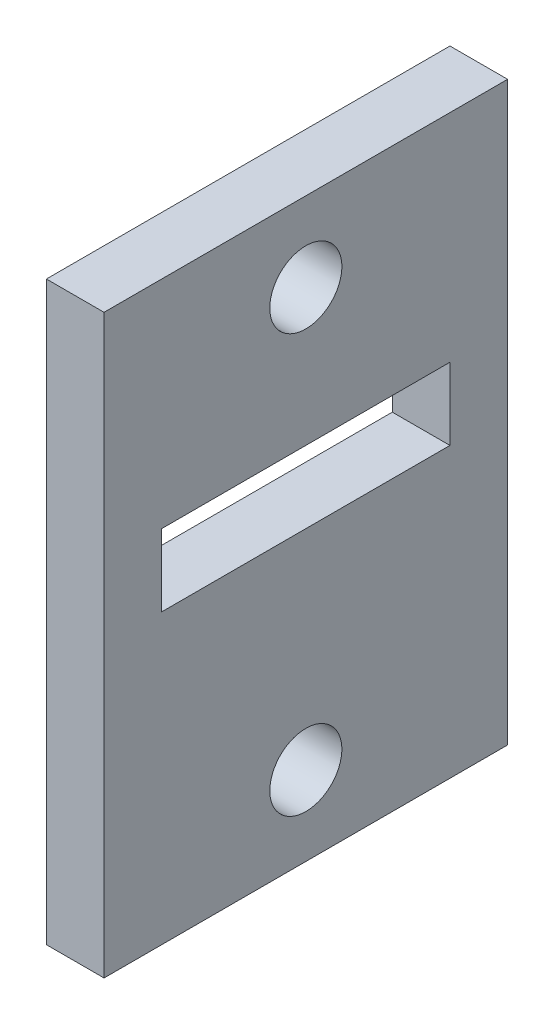
from build123d import *

# Parameters (mm, degrees)
SKETCH1_W           = 14
SKETCH1_H           = 20
SKETCH1_R           = 1.25
BOSS_EXTRUDE1_DEPTH = 2
SKETCH2_W           = 10
SKETCH2_H           = 2.5
CUT_EXTRUDE1_DEPTH  = 2


with BuildPart() as part:
    # Sketch1 → Boss-Extrude1 (new body)
    with BuildSketch(Plane.ZY.offset(64.057810508)):
        with Locations((25, -3.601413474)):
            Rectangle(SKETCH1_W, SKETCH1_H)
        with Locations((25, -10.851413474)):
            Circle(SKETCH1_R, mode=Mode.SUBTRACT)
        with Locations((25, 3.648586526)):
            Circle(SKETCH1_R, mode=Mode.SUBTRACT)
    extrude(amount=BOSS_EXTRUDE1_DEPTH)

    # Sketch2 → Cut-Extrude1 (cut)
    with BuildSketch(Plane.ZY.offset(66.057810508)):
        with Locations((25, -2.351413474)):
            Rectangle(SKETCH2_W, SKETCH2_H)
    extrude(amount=-CUT_EXTRUDE1_DEPTH, mode=Mode.SUBTRACT)


solid = part.part
